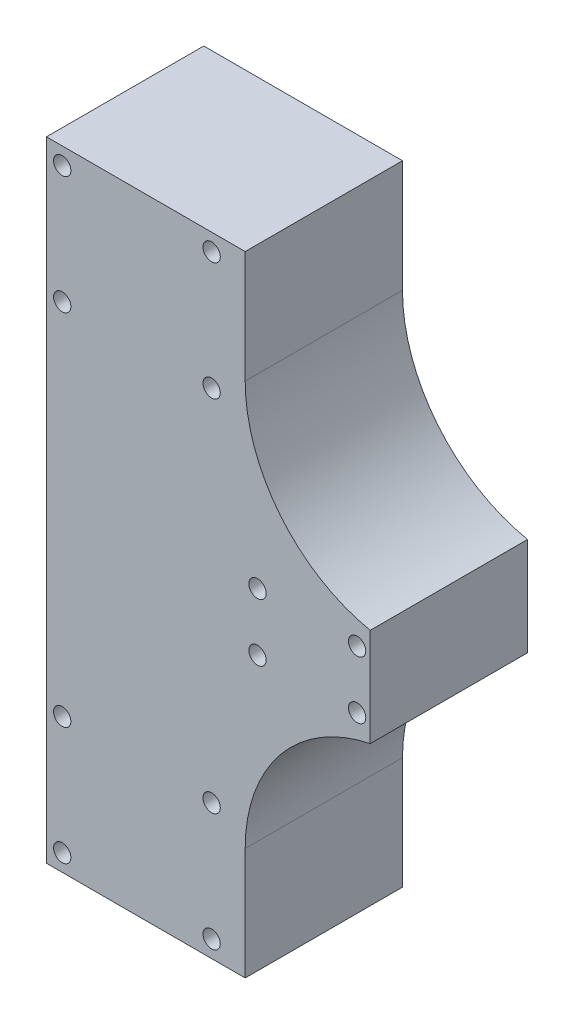
from build123d import *

# Parameters (mm, degrees)
BOSS_EXTRUDE1_DEPTH  = 60
M6_CLEARANCE_HOLE1_D = 6.6


with BuildPart() as part:
    # Sketch1 → Boss-Extrude1 (new body)
    with BuildSketch(Plane.XY):
        with BuildLine():
            Line((971.299999999, 2378.548566852), (895.5, 2378.548566852))
            Line((895.5, 2378.548566852), (895.5, 2258.548566852))
            Line((895.5, 2258.548566852), (895.5, 2138.548566852))
            Line((895.5, 2138.548566852), (971.299999999, 2138.548566852))
            Line((971.299999999, 2138.548566852), (971.299999999, 2181.347801943))
            ThreePointArc((971.299999999, 2181.347801943), (984.737192979, 2219.081914402), (1018.999999999, 2239.829961379))
            Line((1018.999999999, 2239.829961379), (1018.999999999, 2277.267172325))
            ThreePointArc((1018.999999999, 2277.267172325), (984.737192979, 2298.015219302), (971.299999999, 2335.749331762))
            Line((971.299999999, 2335.749331762), (971.299999999, 2378.548566852))
        make_face()
    extrude(amount=BOSS_EXTRUDE1_DEPTH)

    # M6 Clearance Hole1 (through all)
    with Locations(Plane.XY.offset(60)):
        with Locations((901.5, 2145.048566852), (958.5, 2145.048566852), (958.5, 2190.048566852), (901.5, 2190.048566852), (901.5, 2372.048566852), (901.5, 2327.048566852), (958.5, 2327.048566852), (958.5, 2372.048566852), (1013.999999999, 2247.548566852), (1013.999999999, 2269.548566852), (975.999999999, 2247.548566852), (975.999999999, 2269.548566852)):
            Hole(M6_CLEARANCE_HOLE1_D / 2)


solid = part.part
